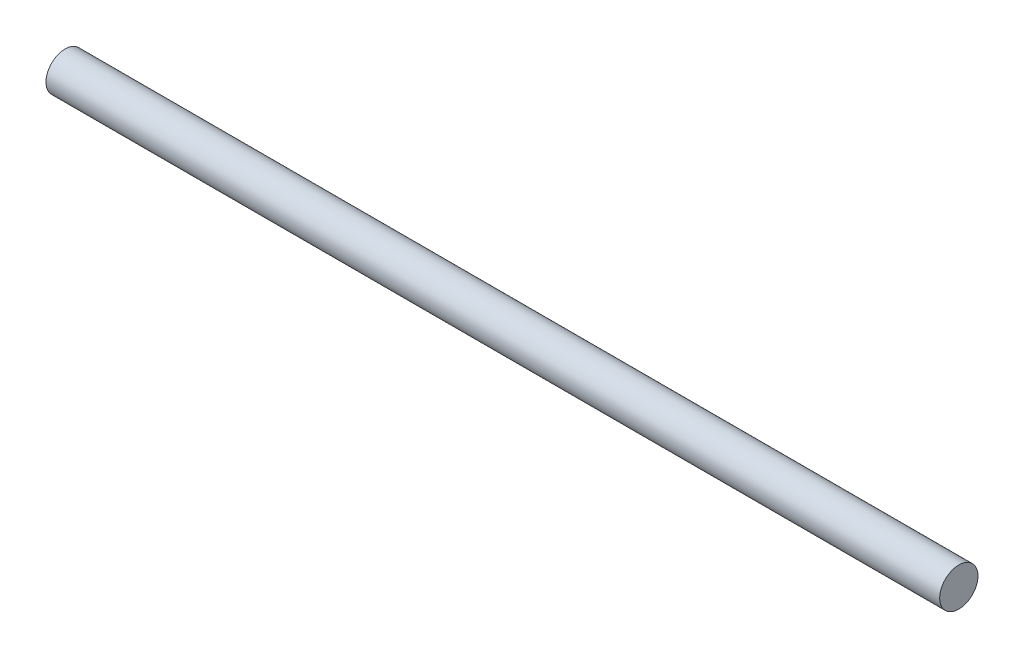
from build123d import *

# Parameters (mm, degrees)
SKETCH1_R           = 1.5
BOSS_EXTRUDE1_DEPTH = 70


with BuildPart() as part:
    # Sketch1 → Boss-Extrude1 (new body)
    with BuildSketch(Plane(origin=(0, 0, 0), x_dir=(0, 0, -1), z_dir=(1, 0, 0))):
        Circle(SKETCH1_R)
    extrude(amount=BOSS_EXTRUDE1_DEPTH)


solid = part.part
